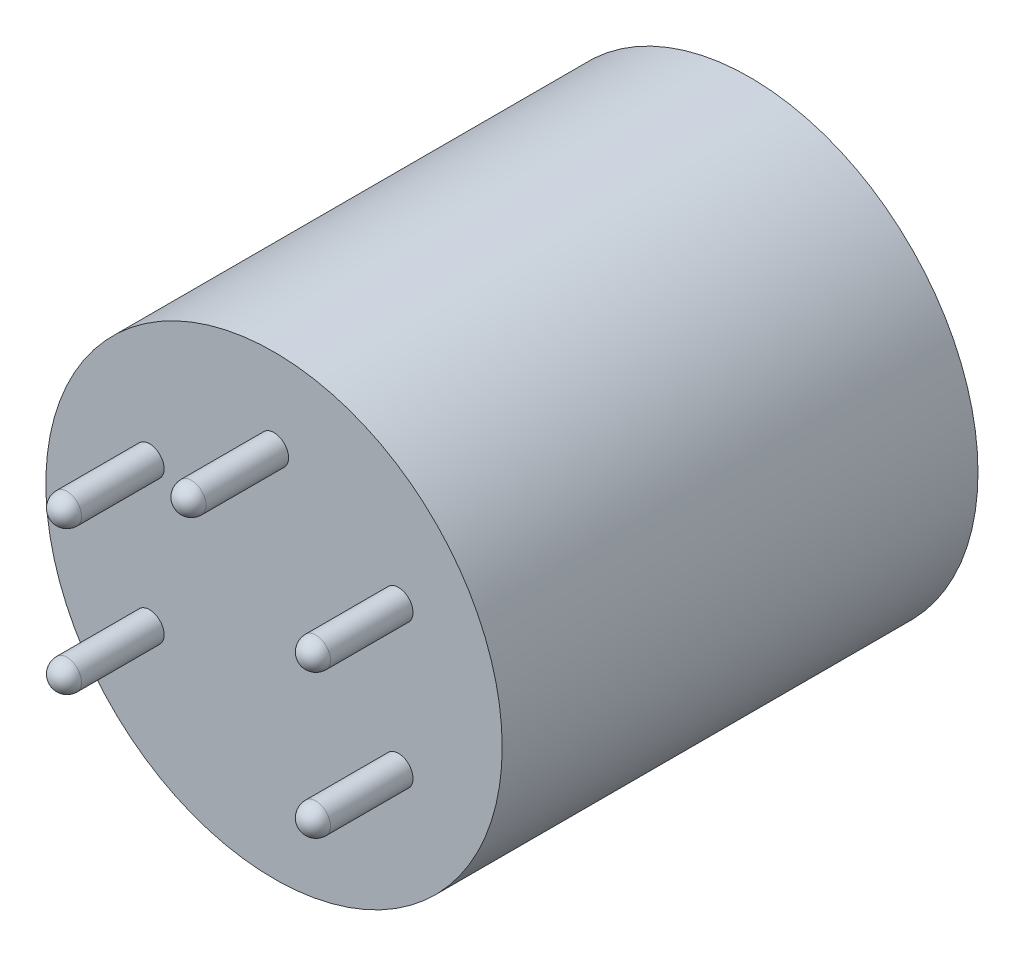
from build123d import *

# Parameters (mm, degrees)
SKETCH_1_R          = 11.75
EXTRUDE_1_DEPTH     = 24.5
SKETCH_2_R          = 0.75
EXTRUDE_2_DEPTH     = 5
FILLET_1_R          = 0.75
SKETCH_3_R          = 7.4
CUT_EXTRUDE_1_DEPTH = 1.5
SKETCH_5_R          = 0.5


with BuildPart() as part:
    # 草图1 → 凸台-拉伸1 (new body)
    with BuildSketch(Plane.XY):
        Circle(SKETCH_1_R)
    extrude(amount=EXTRUDE_1_DEPTH)

    # 草图2 → 凸台-拉伸2 (add)
    with BuildSketch(Plane.XY.offset(24.5)):
        with Locations((-6.408587988, 3.7)):
            Circle(SKETCH_2_R)
        with Locations((0, 7.4)):
            Circle(SKETCH_2_R)
        with Locations((6.408587988, 3.7)):
            Circle(SKETCH_2_R)
        with Locations((6.408587988, -3.7)):
            Circle(SKETCH_2_R)
        with Locations((-6.408587988, -3.7)):
            Circle(SKETCH_2_R)
    extrude(amount=EXTRUDE_2_DEPTH)

    # 圆角1
    fillet_1_edges = [part.edges().sort_by_distance(p)[0] for p in [
        (5.658587988, 3.7, 29.5),
        (5.658587988, -3.7, 29.5),
        (-7.158587988, -3.7, 29.5),
        (-7.158587988, 3.7, 29.5),
        (-0.75, 7.4, 29.5),
    ]]
    fillet(fillet_1_edges, radius=FILLET_1_R)

    # 草图3 → 切除-拉伸1 (cut)
    with BuildSketch(Plane(origin=(0, 0, 0), x_dir=(-1, 0, 0), z_dir=(0, 0, -1))):
        Circle(SKETCH_3_R)
    extrude(amount=-CUT_EXTRUDE_1_DEPTH, mode=Mode.SUBTRACT)

    # 扫描1: sweep along a path in 草图4
    with BuildLine(Plane(origin=(0, 0, 0), x_dir=(-1, 0, 0), z_dir=(0, 0, -1))) as sweep_1_path:
        CenterArc((0, 0), 9.575, 0, 360)
    # 草图5 → 扫描1 (sweep)
    with BuildSketch(Plane(origin=(0, 0, 0), x_dir=(1, 0, 0), z_dir=(0, 1, 0))):
        with Locations((-9.575, 0)):
            Circle(SKETCH_5_R)
    sweep(path=sweep_1_path.line)


solid = part.part
